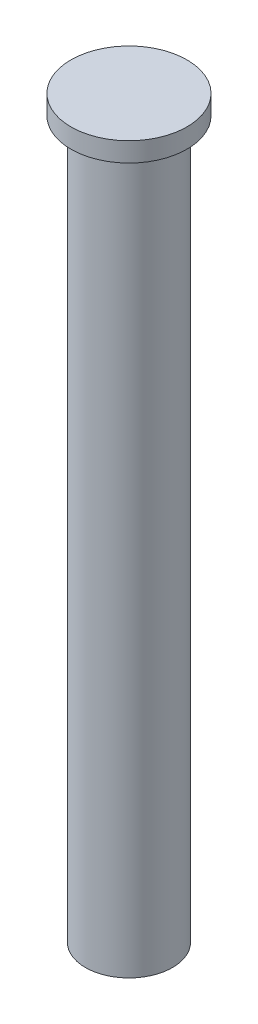
from build123d import *


with BuildPart() as part:
    # Sketch2 → Base-Revolve (revolve)
    with BuildSketch(Plane.XY):
        Polygon((0, 90), (0, -290), (22.5, -290), (22.5, 80), (30, 80), (30, 90), align=None)
    revolve(axis=Axis((0, 90, 0), (0, -1, 0)))


solid = part.part
